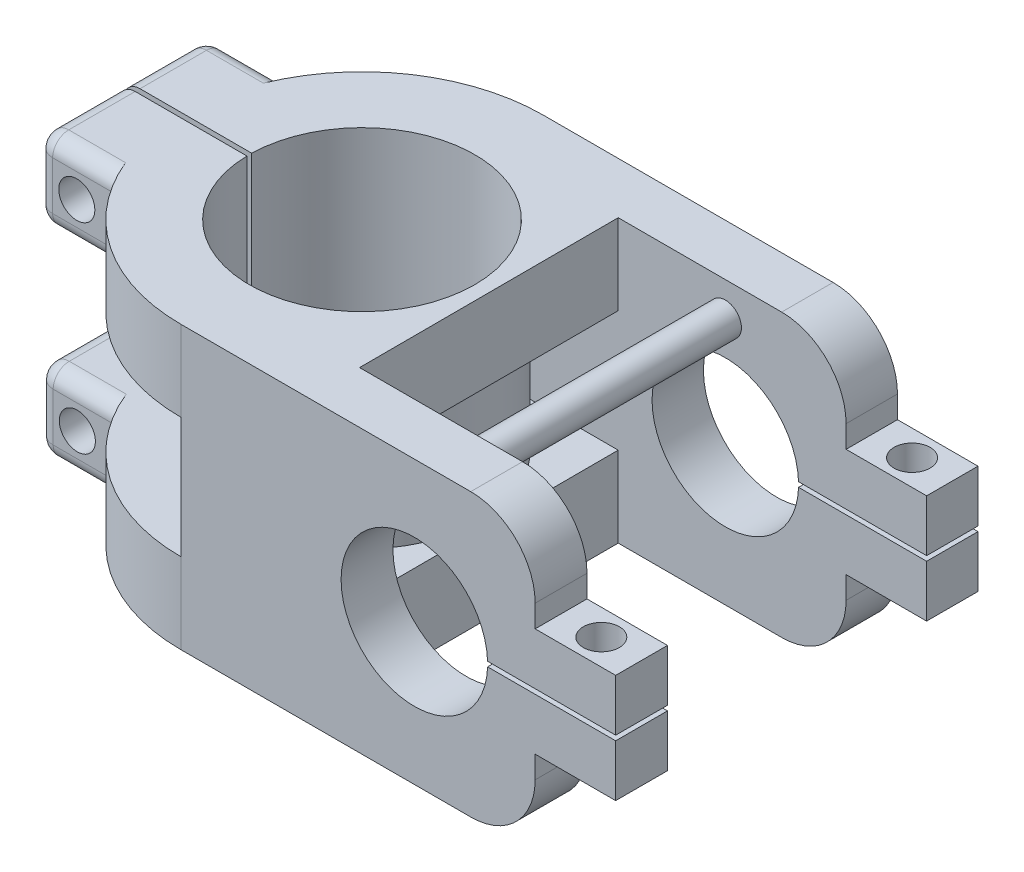
from build123d import *
from build123d.topology import SkipClean

# Parameters (mm, degrees)
SKETCH2_R                 = 28.575
SKETCH2_R_2               = 17.78
BOSS_EXTRUDE3_DEPTH       = 12.7
SKETCH3_W                 = 10.854473524
SKETCH3_H                 = 26.443507434
CUT_EXTRUDE1_DEPTH        = 12.7
CUT_EXTRUDE2_DEPTH        = 12.7
SKETCH5_W                 = 12.840753717
SKETCH5_H                 = 12.7
BOSS_EXTRUDE4_DEPTH       = 12.7
SKETCH6_W                 = 12.840753717
SKETCH6_H                 = 12.7
BOSS_EXTRUDE5_DEPTH       = 12.7
SKETCH7_R                 = 2.8448
CUT_EXTRUDE3_DEPTH        = 33.02
FILLET1_R                 = 2.54
FILLET2_R                 = 2.54
FILLET3_R                 = 2.54
FILLET4_R                 = 2.54
FILLET5_R                 = 2.54
FILLET6_R                 = 2.54
SKETCH8_R                 = 18.738819316
SKETCH8_R_2               = 17.78
BOSS_EXTRUDE6_DEPTH       = 19.05
SKETCH9_R                 = 28.575
BOSS_EXTRUDE7_DEPTH       = 12.7
SKETCH12_W                = 11.37566774
SKETCH12_H                = 26.806734356
CUT_EXTRUDE4_DEPTH        = 12.7
SKETCH13_W                = 26.806734356
SKETCH13_H                = 12.7
BOSS_EXTRUDE8_DEPTH       = 12.7
SKETCH14_R                = 17.78
CUT_EXTRUDE5_DEPTH        = 12.7
CUT_EXTRUDE6_DEPTH        = 12.7
SKETCH16_W                = 20.93971863
SKETCH16_H                = 0.381
CUT_EXTRUDE7_DEPTH        = 12.7
FILLET7_R                 = 2.54
FILLET8_R                 = 2.54
FILLET9_R                 = 2.54
FILLET10_R                = 2.54
FILLET11_R                = 2.54
FILLET12_R                = 2.54
SKETCH17_R                = 2.8448
CUT_EXTRUDE8_DEPTH        = 29.464
SKETCH19_W                = 1.827097527
SKETCH19_H                = 0.762
CUT_EXTRUDE13_DEPTH       = 29.464
SKETCH22_W                = 55.88
SKETCH22_H                = 8.17709812
BOSS_EXTRUDE12_DEPTH      = 31.75
BOSS_EXTRUDE12_DEPTH_BACK = 12.7
SKETCH23_W                = 55.88
SKETCH23_H                = 8.104128776
BOSS_EXTRUDE13_DEPTH      = 31.75
BOSS_EXTRUDE13_DEPTH_BACK = 12.7
SKETCH24_R                = 11.557
CUT_EXTRUDE14_DEPTH       = 67.31
FILLET13_R                = 10.16
FILLET14_R                = 10.16
FILLET15_R                = 10.16
FILLET16_R                = 10.16
CUT_EXTRUDE15_DEPTH       = 67.31
SKETCH26_R                = 2.54
BOSS_EXTRUDE14_DEPTH      = 43.434
SKETCH27_W                = 10.889060874
SKETCH27_H                = 0.381
CUT_EXTRUDE16_DEPTH       = 64.516
SKETCH28_W                = 8.900082699
SKETCH28_H                = 0.381
CUT_EXTRUDE17_DEPTH       = 64.516
SKETCH29_W                = 8.17709812
SKETCH29_H                = 8.1770982
BOSS_EXTRUDE15_DEPTH      = 12.7
SKETCH30_W                = 8.17709812
SKETCH30_H                = 8.1770982
BOSS_EXTRUDE16_DEPTH      = 12.7
SKETCH31_R                = 2.8448
CUT_EXTRUDE18_DEPTH       = 22.098
SKETCH34_W                = 8.104128776
SKETCH34_H                = 8.1770982
BOSS_EXTRUDE17_DEPTH      = 12.7
SKETCH35_W                = 8.104128776
SKETCH35_H                = 8.1770982
BOSS_EXTRUDE18_DEPTH      = 12.7
SKETCH36_R                = 2.8448
CUT_EXTRUDE19_DEPTH       = 27.686


with BuildPart() as part:
    # Sketch2 → Boss-Extrude3 (new body)
    with BuildSketch(Plane(origin=(0, 0, 0), x_dir=(1, 0, 0), z_dir=(0, 1, 0))):
        with Locations(Location((0, 0, 0), (0, 0, 270))):
            Circle(SKETCH2_R)
        with Locations(Location((0, 0, 0), (0, 0, 270))):
            Circle(SKETCH2_R_2, mode=Mode.SUBTRACT)
    extrude(amount=BOSS_EXTRUDE3_DEPTH)

    # Sketch3 → Cut-Extrude1 (cut)
    with BuildSketch(Plane(origin=(0, 12.7, 0), x_dir=(1, 0, 0), z_dir=(0, 1, 0))):
        with Locations((-30.759347879, 0)):
            Rectangle(SKETCH3_W, SKETCH3_H)
    extrude(amount=-CUT_EXTRUDE1_DEPTH, mode=Mode.SUBTRACT)

    # Sketch4 → Cut-Extrude2 (cut)
    with BuildSketch(Plane(origin=(0, 12.7, 0), x_dir=(1, 0, 0), z_dir=(0, 1, 0))):
        Polygon((-16.376768267, 0), (-16.376768267, 0.381), (-26.003615217, 0.381), (-26.003615217, -0.381), (-16.376768267, -0.381), align=None)
    extrude(amount=-CUT_EXTRUDE2_DEPTH, mode=Mode.SUBTRACT)

    # Sketch5 → Boss-Extrude4 (add)
    with BuildSketch(Plane.ZY.offset(25.332111117)):
        with Locations((6.801376859, 6.35)):
            Rectangle(SKETCH5_W, SKETCH5_H)
    extrude(amount=BOSS_EXTRUDE4_DEPTH)

    # Sketch6 → Boss-Extrude5 (add)
    with BuildSketch(Plane.ZY.offset(25.332111117)):
        with Locations((-6.801376859, 6.35)):
            Rectangle(SKETCH6_W, SKETCH6_H)
    extrude(amount=BOSS_EXTRUDE5_DEPTH)

    # Sketch7 → Cut-Extrude3 (cut)
    with BuildSketch(Plane.XY.offset(13.221753717)):
        with Locations((-31.682111117, 6.35)):
            Circle(SKETCH7_R)
    extrude(amount=-CUT_EXTRUDE3_DEPTH, mode=Mode.SUBTRACT)

    # Fillet1
    fillet1_edges = [part.edges().sort_by_distance(p)[0] for p in [
        (-38.032111117, 6.35, 13.221753717),
    ]]
    fillet(fillet1_edges, radius=FILLET1_R)

    # Fillet2
    fillet2_edges = [part.edges().sort_by_distance(p)[0] for p in [
        (-38.032111117, 6.35, -13.221753717),
    ]]
    fillet(fillet2_edges, radius=FILLET2_R)

    # Fillet3
    fillet3_edges = [part.edges().sort_by_distance(p)[0] for p in [
        (-30.412111117, 12.7, -13.221753717),
        (-37.288162341, 12.7, -12.477804942),
        (-38.032111117, 12.7, -5.531376859),
    ]]
    fillet(fillet3_edges, radius=FILLET3_R)

    # Fillet4
    fillet4_edges = [part.edges().sort_by_distance(p)[0] for p in [
        (-38.032111117, 12.7, 5.531376859),
        (-30.412111117, 12.7, 13.221753717),
        (-37.288162341, 12.7, 12.477804942),
    ]]
    fillet(fillet4_edges, radius=FILLET4_R)

    # Fillet5
    fillet5_edges = [part.edges().sort_by_distance(p)[0] for p in [
        (-30.412111117, 0, -13.221753717),
        (-37.288162341, 0, -12.477804942),
        (-38.032111117, 0, -5.531376859),
    ]]
    fillet(fillet5_edges, radius=FILLET5_R)

    # Fillet6
    fillet6_edges = [part.edges().sort_by_distance(p)[0] for p in [
        (-38.032111117, 0, 5.531376859),
        (-30.412111117, 0, 13.221753717),
        (-37.288162341, 0, 12.477804942),
    ]]
    fillet(fillet6_edges, radius=FILLET6_R)

    # Sketch8 → Boss-Extrude6 (add)
    with BuildSketch(Plane(origin=(0, 12.7, 0), x_dir=(1, 0, 0), z_dir=(0, 1, 0))):
        with Locations(Location((0, 0, 0), (0, 0, 178.834974821))):
            Circle(SKETCH8_R)
        with Locations(Location((0, 0, 0), (0, 0, 178.772139315))):
            Circle(SKETCH8_R_2, mode=Mode.SUBTRACT)
    extrude(amount=BOSS_EXTRUDE6_DEPTH)

    # Sketch9 → Boss-Extrude7 (add)
    with BuildSketch(Plane(origin=(0, 31.75, 0), x_dir=(1, 0, 0), z_dir=(0, 1, 0))):
        with Locations(Location((0, 0, 0), (0, 0, 270))):
            Circle(SKETCH9_R)
    extrude(amount=BOSS_EXTRUDE7_DEPTH)

    # Sketch12 → Cut-Extrude4 (cut)
    with BuildSketch(Plane(origin=(0, 44.45, 0), x_dir=(1, 0, 0), z_dir=(0, 1, 0))):
        with Locations((-30.924322796, 0)):
            Rectangle(SKETCH12_W, SKETCH12_H)
    extrude(amount=-CUT_EXTRUDE4_DEPTH, mode=Mode.SUBTRACT)

    # Sketch13 → Boss-Extrude8 (add)
    with BuildSketch(Plane.ZY.offset(25.236488926)):
        with Locations((0, 38.1)):
            Rectangle(SKETCH13_W, SKETCH13_H)
    extrude(amount=BOSS_EXTRUDE8_DEPTH)

    # Sketch14 → Cut-Extrude5 (cut)
    with BuildSketch(Plane(origin=(0, 44.45, 0), x_dir=(1, 0, 0), z_dir=(0, 1, 0))):
        with Locations(Location((0, 0, 0), (0, 0, 178.772139315))):
            Circle(SKETCH14_R)
    extrude(amount=-CUT_EXTRUDE5_DEPTH, mode=Mode.SUBTRACT)

    # Sketch15 → Cut-Extrude6 (cut)
    with BuildSketch(Plane(origin=(0, 44.45, 0), x_dir=(1, 0, 0), z_dir=(0, 1, 0))):
        with BuildLine():
            Line((-37.936488926, 0.381), (-37.936488926, 0))
            Line((-37.936488926, 0), (-17.78, 0))
            ThreePointArc((-17.78, 0), (-17.778979318, 0.190510937), (-17.775917388, 0.381))
            Line((-17.775917388, 0.381), (-37.936488926, 0.381))
        make_face()
    extrude(amount=-CUT_EXTRUDE6_DEPTH, mode=Mode.SUBTRACT)

    # Sketch16 → Cut-Extrude7 (cut)
    with BuildSketch(Plane(origin=(0, 44.45, 0), x_dir=(1, 0, 0), z_dir=(0, 1, 0))):
        with Locations((-27.466629611, -0.1905)):
            Rectangle(SKETCH16_W, SKETCH16_H)
    extrude(amount=-CUT_EXTRUDE7_DEPTH, mode=Mode.SUBTRACT)

    # Fillet7
    fillet7_edges = [part.edges().sort_by_distance(p)[0] for p in [
        (-37.936488926, 44.45, -6.892183589),
    ]]
    fillet(fillet7_edges, radius=FILLET7_R)

    # Fillet8
    fillet8_edges = [part.edges().sort_by_distance(p)[0] for p in [
        (-37.936488926, 44.45, 6.892183589),
    ]]
    fillet(fillet8_edges, radius=FILLET8_R)

    # Fillet9
    fillet9_edges = [part.edges().sort_by_distance(p)[0] for p in [
        (-37.936488926, 31.75, -6.892183589),
    ]]
    fillet(fillet9_edges, radius=FILLET9_R)

    # Fillet10
    fillet10_edges = [part.edges().sort_by_distance(p)[0] for p in [
        (-37.936488926, 31.75, 6.892183589),
    ]]
    fillet(fillet10_edges, radius=FILLET10_R)

    # Fillet11
    fillet11_edges = [part.edges().sort_by_distance(p)[0] for p in [
        (-30.316488926, 44.45, 13.403367178),
        (-37.19254015, 43.706051224, 13.403367178),
        (-37.936488926, 38.1, 13.403367178),
        (-30.316488926, 31.75, 13.403367178),
        (-37.19254015, 32.493948776, 13.403367178),
    ]]
    fillet(fillet11_edges, radius=FILLET11_R)

    # Fillet12
    fillet12_edges = [part.edges().sort_by_distance(p)[0] for p in [
        (-37.936488926, 38.1, -13.403367178),
        (-30.316488926, 44.45, -13.403367178),
        (-37.19254015, 43.706051224, -13.403367178),
        (-30.316488926, 31.75, -13.403367178),
        (-37.19254015, 32.493948776, -13.403367178),
    ]]
    fillet(fillet12_edges, radius=FILLET12_R)

    # Sketch17 → Cut-Extrude8 (cut)
    with BuildSketch(Plane.XY.offset(13.403367178)):
        with Locations((-31.586488926, 38.1)):
            Circle(SKETCH17_R)
    extrude(amount=-CUT_EXTRUDE8_DEPTH, mode=Mode.SUBTRACT)

    # Sketch19 → Cut-Extrude13 (cut)
    with BuildSketch(Plane(origin=(0, 31.75, 0), x_dir=(1, 0, 0), z_dir=(0, 1, 0))):
        with Locations((-17.821396883, 0)):
            Rectangle(SKETCH19_W, SKETCH19_H)
    extrude(amount=-CUT_EXTRUDE13_DEPTH, mode=Mode.SUBTRACT)


with BuildPart() as cut_extrude13_kept_piece:
    # of the separate pieces the step leaves, the one the design keeps (cut_extrude13_pieces_kept)
    add(part.part.solids().sort_by_distance((-35.396488926, 31.75, -10.863367178))[0])

    # Sketch22 → Boss-Extrude12 (add, two sides)
    with BuildSketch(Plane(origin=(0, 12.7, 0), x_dir=(1, 0, 0), z_dir=(0, 1, 0))) as boss_extrude12_sk:
        with Locations((27.94, -24.48645094)):
            Rectangle(SKETCH22_W, SKETCH22_H)
    extrude(amount=BOSS_EXTRUDE12_DEPTH)
    extrude(boss_extrude12_sk.sketch, amount=-BOSS_EXTRUDE12_DEPTH_BACK)

    # Sketch23 → Boss-Extrude13 (add, two sides)
    with BuildSketch(Plane(origin=(0, 12.7, 0), x_dir=(1, 0, 0), z_dir=(0, 1, 0))) as boss_extrude13_sk:
        with Locations((27.94, 24.522935612)):
            Rectangle(SKETCH23_W, SKETCH23_H)
    extrude(amount=BOSS_EXTRUDE13_DEPTH)
    extrude(boss_extrude13_sk.sketch, amount=-BOSS_EXTRUDE13_DEPTH_BACK)

    # Sketch24 → Cut-Extrude14 (cut)
    with BuildSketch(Plane(origin=(0, 0, -28.575), x_dir=(-1, 0, 0), z_dir=(0, 0, -1))):
        with Locations((-36.83, 22.225)):
            Circle(SKETCH24_R)
    extrude(amount=-CUT_EXTRUDE14_DEPTH, mode=Mode.SUBTRACT)

    # Fillet13
    fillet13_edges = [cut_extrude13_kept_piece.edges().sort_by_distance(p)[0] for p in [
        (55.88, 44.45, 24.48645094),
    ]]
    fillet(fillet13_edges, radius=FILLET13_R)

    # Fillet14
    fillet14_edges = [cut_extrude13_kept_piece.edges().sort_by_distance(p)[0] for p in [
        (55.88, 0, 24.48645094),
    ]]
    fillet(fillet14_edges, radius=FILLET14_R)

    # Fillet15
    fillet15_edges = [cut_extrude13_kept_piece.edges().sort_by_distance(p)[0] for p in [
        (55.88, 44.45, -24.522935612),
    ]]
    fillet(fillet15_edges, radius=FILLET15_R)

    # Fillet16
    fillet16_edges = [cut_extrude13_kept_piece.edges().sort_by_distance(p)[0] for p in [
        (55.88, 0, -24.522935612),
    ]]
    fillet(fillet16_edges, radius=FILLET16_R)

    # Sketch25 → Cut-Extrude15 (cut)
    with SkipClean():  # the faces are left unmerged after this step: merging them gives an invalid solid
        with BuildSketch(Plane(origin=(0, 44.45, 0), x_dir=(1, 0, 0), z_dir=(0, 1, 0))):
            Polygon((28.57495233, 0.052195041), (28.57495233, 20.470871224), (19.936751399, 20.470871224), (20.011402347, -20.39790188), (28.575, -20.39790188), align=None)
        extrude(amount=-CUT_EXTRUDE15_DEPTH, mode=Mode.SUBTRACT)


with BuildPart() as body_2:
    # of the pieces the cut leaves, the one that is kept (cut_extrude15_keep)
    add(cut_extrude13_kept_piece.part.solids().sort_by_distance((55.88, 10.16, -20.470871224))[0])

    # Sketch26 → Boss-Extrude14 (add)
    with SkipClean():  # the faces are left unmerged after this step: merging them gives an invalid solid
        with BuildSketch(Plane.XY.offset(-20.470871224)):
            with Locations(Location((36.83, 39.116, 0), (0, 0, 180))):
                Circle(SKETCH26_R)
        extrude(amount=BOSS_EXTRUDE14_DEPTH)

    # Sketch27 → Cut-Extrude16 (cut)
    with SkipClean():  # the faces are left unmerged after this step: merging them gives an invalid solid
        with BuildSketch(Plane.XY.offset(28.575)):
            with Locations((52.414940452, 22.4155)):
                Rectangle(SKETCH27_W, SKETCH27_H)
        extrude(amount=-CUT_EXTRUDE16_DEPTH, mode=Mode.SUBTRACT)

    # Sketch28 → Cut-Extrude17 (cut)
    with SkipClean():  # the faces are left unmerged after this step: merging them gives an invalid solid
        with BuildSketch(Plane.XY.offset(28.575)):
            with Locations((52.021010234, 22.0345)):
                Rectangle(SKETCH28_W, SKETCH28_H)
        extrude(amount=-CUT_EXTRUDE17_DEPTH, mode=Mode.SUBTRACT)

    # Sketch29 → Boss-Extrude15 (add)
    with SkipClean():  # the faces are left unmerged after this step: merging them gives an invalid solid
        with BuildSketch(Plane(origin=(55.88, 0, 0), x_dir=(0, 0, -1), z_dir=(1, 0, 0))):
            with Locations((-24.48645094, 26.6945491)):
                Rectangle(SKETCH29_W, SKETCH29_H)
        extrude(amount=BOSS_EXTRUDE15_DEPTH)

    # Sketch30 → Boss-Extrude16 (add)
    with SkipClean():  # the faces are left unmerged after this step: merging them gives an invalid solid
        with BuildSketch(Plane(origin=(55.88, 0, 0), x_dir=(0, 0, -1), z_dir=(1, 0, 0))):
            with Locations((-24.48645094, 17.7554509)):
                Rectangle(SKETCH30_W, SKETCH30_H)
        extrude(amount=BOSS_EXTRUDE16_DEPTH)

    # Sketch31 → Cut-Extrude18 (cut)
    with SkipClean():  # the faces are left unmerged after this step: merging them gives an invalid solid
        with BuildSketch(Plane(origin=(0, 30.7830982, 0), x_dir=(1, 0, 0), z_dir=(0, 1, 0))):
            with Locations(Location((62.23, -24.48645094, 0), (0, 0, 270))):
                Circle(SKETCH31_R)
        extrude(amount=-CUT_EXTRUDE18_DEPTH, mode=Mode.SUBTRACT)

    # Sketch34 → Boss-Extrude17 (add)
    with SkipClean():  # the faces are left unmerged after this step: merging them gives an invalid solid
        with BuildSketch(Plane(origin=(55.88, 0, 0), x_dir=(0, 0, -1), z_dir=(1, 0, 0))):
            with Locations((24.522935612, 26.6945491)):
                Rectangle(SKETCH34_W, SKETCH34_H)
        extrude(amount=BOSS_EXTRUDE17_DEPTH)

    # Sketch35 → Boss-Extrude18 (add)
    with SkipClean():  # the faces are left unmerged after this step: merging them gives an invalid solid
        with BuildSketch(Plane(origin=(55.88, 0, 0), x_dir=(0, 0, -1), z_dir=(1, 0, 0))):
            with Locations((24.522935612, 17.7554509)):
                Rectangle(SKETCH35_W, SKETCH35_H)
        extrude(amount=BOSS_EXTRUDE18_DEPTH)

    # Sketch36 → Cut-Extrude19 (cut)
    with SkipClean():  # the faces are left unmerged after this step: merging them gives an invalid solid
        with BuildSketch(Plane(origin=(0, 30.7830982, 0), x_dir=(1, 0, 0), z_dir=(0, 1, 0))):
            with Locations(Location((62.23, 24.522935612, 0), (0, 0, 270))):
                Circle(SKETCH36_R)
        extrude(amount=-CUT_EXTRUDE19_DEPTH, mode=Mode.SUBTRACT)


solid = body_2.part
